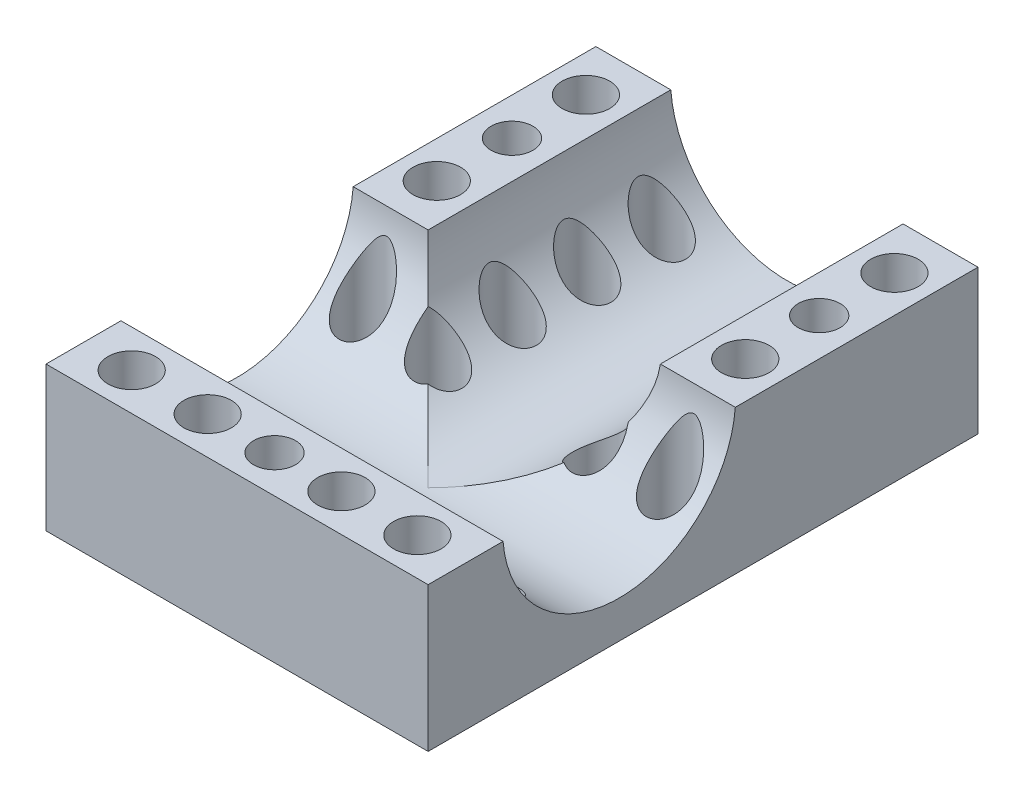
from build123d import *

# Parameters (mm, degrees)
EXTRUDE_1_DEPTH       = 15.5
CUT_EXTRUDE_1_DEPTH   = 42
CUT_EXTRUDE_2_DEPTH   = 38.5
M4X0_71_D             = 3.3
HOLE_WIZARD_1_4_201_D = 5.1054
HOLE_WIZARD_1_4_202_D = 5.1054
HOLE_WIZARD_1_4_203_D = 5.1054
SKETCH_31_R           = 2.25
CUT_EXTRUDE_4_DEPTH   = 16.5000001
HOLE_WIZARD_1_4_204_D = 5.1054


with BuildPart() as part:
    # Эскиз1 → Бобышка-Вытянуть1 (new body)
    with BuildSketch(Plane(origin=(0, 0, 0), x_dir=(1, 0, 0), z_dir=(0, 1, 0))):
        Polygon((0, 0), (8, 0), (33, 0), (41, 0), (41, 59), (0, 59), (0, 51), (0, 41), (0, 33), (0, 8), align=None)
    extrude(amount=EXTRUDE_1_DEPTH)

    # Эскиз4 → Вырез-Вытянуть1 (cut, through all)
    with BuildSketch(Plane.ZY):
        with BuildLine():
            Line((-33, 16.5), (-8, 16.5))
            ThreePointArc((-8, 16.5), (-20.5, 4), (-33, 16.5))
        make_face()
    extrude(amount=-CUT_EXTRUDE_1_DEPTH, mode=Mode.SUBTRACT)

    # Эскиз5 → Вырез-Вытянуть2 (cut)
    with BuildSketch(Plane(origin=(0, 0, -59), x_dir=(-1, 0, 0), z_dir=(0, 0, -1))):
        with BuildLine():
            Line((-33, 16.5), (-8, 16.5))
            ThreePointArc((-8, 16.5), (-20.5, 4), (-33, 16.5))
        make_face()
    extrude(amount=-CUT_EXTRUDE_2_DEPTH, mode=Mode.SUBTRACT)

    # Отверстие обработанное метчиком M4x0.71 (through all)
    with Locations(Plane(origin=(0, 15.5, 0), x_dir=(1, 0, 0), z_dir=(0, 1, 0))):
        with Locations((4.020032103, 45.979967897), (36.979967897, 45.979967897), (20.5, 4.020032103)):
            Hole(M4X0_71_D / 2)

    # Отверстие обработанное метчиком 1/4-201 (through all)
    with Locations(Plane(origin=(0, 15.5, 0), x_dir=(1, 0, 0), z_dir=(0, 1, 0))):
        with Locations((3.950002683, 53.979661384), (37.049997317, 53.979661384), (37.049997317, 37.980274411), (3.950002683, 37.980274411), (5.175, 4.020032103), (13.325, 4.020032103), (27.675, 4.020032103), (35.825, 4.020032103)):
            Hole(HOLE_WIZARD_1_4_201_D / 2)

    # Отверстие обработанное метчиком 1/4-202 (through all)
    with Locations(Plane(origin=(0, 15.5, 0), x_dir=(1, 0, 0), z_dir=(0, 1, 0))):
        with Locations((4.020032103, 29.980580924), (36.979967897, 29.980580924), (35.825, 12.020032103), (5.175, 12.020032103)):
            Hole(HOLE_WIZARD_1_4_202_D / 2)

    # Отверстие обработанное метчиком 1/4-203 (through all)
    with Locations(Plane(origin=(0, 15.5, 0), x_dir=(1, 0, 0), z_dir=(0, 1, 0))):
        with Locations((12.020032103, 54.05), (12.020032103, 46.05), (12.020032103, 38.05), (12.020032103, 30.05), (28.979967897, 54.05), (28.979967897, 46.05), (28.979967897, 38.05), (28.979967897, 30.05)):
            Hole(HOLE_WIZARD_1_4_203_D / 2)

    # Эскиз31 → Вырез-Вытянуть4 (cut, through all)
    with BuildSketch(Plane.XZ):
        with Locations((4.020032103, -45.979967897)):
            Circle(SKETCH_31_R)
        with Locations((36.979967897, -45.979967897)):
            Circle(SKETCH_31_R)
        with Locations((20.5, -4.020032103)):
            Circle(SKETCH_31_R)
    extrude(amount=-CUT_EXTRUDE_4_DEPTH, mode=Mode.SUBTRACT)

    # Отверстие обработанное метчиком 1/4-204 (through all)
    with Locations(Plane(origin=(0, 15.5, 0), x_dir=(1, 0, 0), z_dir=(0, 1, 0))):
        with Locations((27.675, 11.95), (13.325, 11.95), (20.5, 11.95)):
            Hole(HOLE_WIZARD_1_4_204_D / 2)


solid = part.part
